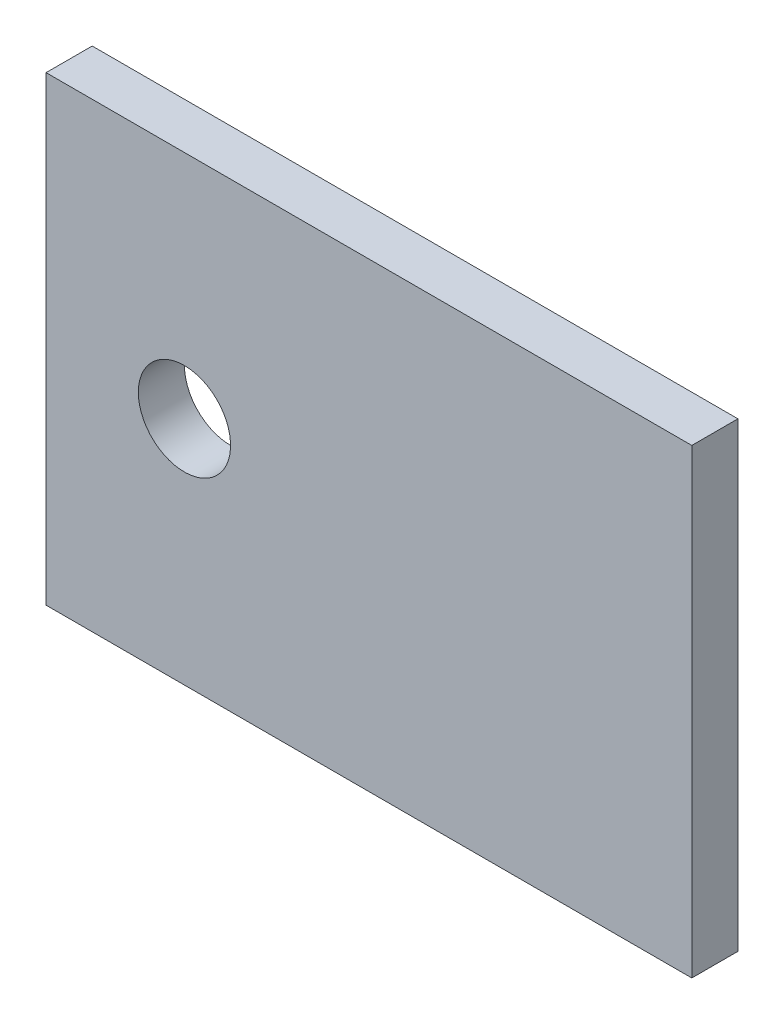
from build123d import *

# Parameters (mm, degrees)
PLAT_W                          = 50
PLAT_H                          = 5
EL_MENT_M_CANO_SOUD_1_DEPTH     = 70
DIAM_TRE_DU_PER_AGE_10_0_10_1_D = 10


with BuildPart() as part:
    # plat → Elément mécano-soudé1 (new body)
    with BuildSketch(Plane.YZ.offset(-35)):
        Rectangle(PLAT_W, PLAT_H)
    extrude(amount=EL_MENT_M_CANO_SOUD_1_DEPTH)

    # Diamètre du perçage Ø10.0 (10)1 (through all)
    with Locations(Plane(origin=(0, 0, -2.5), x_dir=(-1, 0, 0), z_dir=(0, 0, -1))):
        with Locations((20, 0)):
            Hole(DIAM_TRE_DU_PER_AGE_10_0_10_1_D / 2)


solid = part.part
